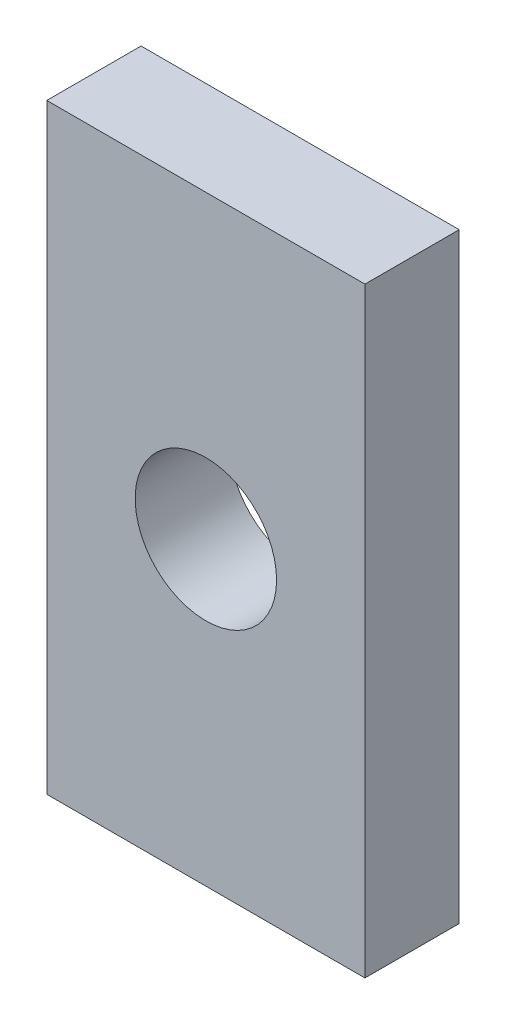
from build123d import *

# Parameters (mm, degrees)
SKETCH1_W           = 40.5
SKETCH1_H           = 76.5
BOSS_EXTRUDE1_DEPTH = 12
CUT_EXTRUDE1_REACH  = 14
SKETCH2_R           = 9


with BuildPart() as part:
    # Sketch1 → Boss-Extrude1 (new body)
    with BuildSketch(Plane.XY):
        Rectangle(SKETCH1_W, SKETCH1_H)
    extrude(amount=BOSS_EXTRUDE1_DEPTH)

    # Sketch2 → Cut-Extrude1 (cut, up to next)
    with BuildSketch(Plane.XY.offset(12), mode=Mode.PRIVATE) as cut_extrude1_sk1:
        Circle(SKETCH2_R)
    cut_extrude1_tool1 = extrude(cut_extrude1_sk1.sketch, amount=-CUT_EXTRUDE1_REACH, mode=Mode.PRIVATE) & part.part
    add(cut_extrude1_tool1.solids().sort_by_distance((0, 0, 12))[0], mode=Mode.SUBTRACT)


solid = part.part
